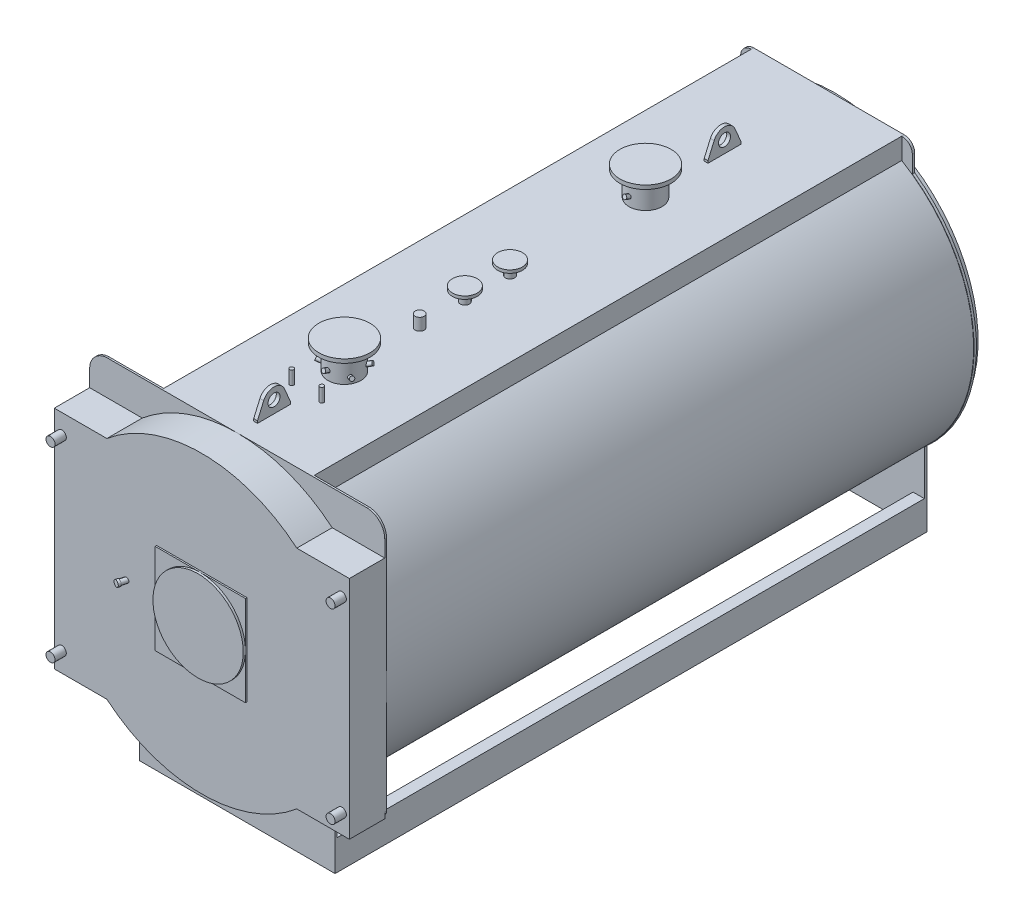
from build123d import *

# Parameters (mm, degrees)
PIASTRA_ANTERIORE_DEPTH       = 12
CORPO_DEPTH                   = 3902
PIASTRA_POSTERIORE_DEPTH      = 16
BASAMENTO_DEPTH               = 3902
ESTRUSIONE_ESTRUSIONE3_DEPTH  = 235
SCHIZZO8_W                    = 600
SCHIZZO8_H                    = 600
ESTRUSIONE_ESTRUSIONE4_DEPTH  = 10
SCHIZZO9_R                    = 300
ESTRUSIONE_ESTRUSIONE5_DEPTH  = 15
SCHIZZO12_R                   = 30
ESTRUSIONE_ESTRUSIONE6_DEPTH  = 75
SCHIZZO13_R                   = 109.55
ESTRUSIONE_ESTRUSIONE7_DEPTH  = 1170
SCHIZZO14_R                   = 170
ESTRUSIONE_ESTRUSIONE8_DEPTH  = 26
SCHIZZO13_3_R                 = 30.15
ESTRUSIONE_ESTRUSIONE9_DEPTH  = 1070
SCHIZZO15_R                   = 82.5
ESTRUSIONE_ESTRUSIONE10_DEPTH = 20
SCHIZZO13_4_R                 = 30.15
ESTRUSIONE_ESTRUSIONE11_DEPTH = 1060
SCHIZZO13_5_R                 = 13.35
ESTRUSIONE_ESTRUSIONE12_DEPTH = 1070
RIPETIZIONECIRCOLARE1_COUNT   = 3
SCHIZZO21_R                   = 24.15
ESTRUSIONE_ESTRUSIONE13_DEPTH = 149
SCHIZZO21_3_R                 = 24.15
ESTRUSIONE_ESTRUSIONE14_DEPTH = 50
SCHIZZO22_R                   = 75
ESTRUSIONE_ESTRUSIONE15_DEPTH = 16
SCHIZZO23_R                   = 40
GOLFARE_DEPTH                 = 12.5


with BuildPart() as part:
    # Schizzo1 → piastra anteriore (new body)
    with BuildSketch(Plane.XY):
        with BuildLine():
            Line((-860, 2210), (860, 2210))
            ThreePointArc((860, 2210), (944.852813742, 2174.852813742), (980, 2090))
            Line((980, 2090), (980, 520))
            ThreePointArc((980, 520), (968.284271247, 491.715728753), (940, 480))
            Line((940, 480), (650, 480))
            Line((650, 480), (650, 0))
            Line((650, 0), (-650, 0))
            Line((-650, 0), (-650, 480))
            Line((-650, 480), (-940, 480))
            ThreePointArc((-940, 480), (-968.284271247, 491.715728753), (-980, 520))
            Line((-980, 520), (-980, 2090))
            ThreePointArc((-980, 2090), (-944.852813742, 2174.852813742), (-860, 2210))
        make_face()
    extrude(amount=-PIASTRA_ANTERIORE_DEPTH)

    # Schizzo2 → corpo (add)
    with BuildSketch(Plane(origin=(0, 0, -12), x_dir=(-1, 0, 0), z_dir=(0, 0, -1))):
        with BuildLine():
            Line((500, 2069.944194575), (500, 2210))
            Line((500, 2210), (-500, 2210))
            Line((-500, 2210), (-500, 2069.944194575))
            ThreePointArc((-500, 2069.944194575), (0, 252.5), (500, 2069.944194575))
        make_face()
        with BuildLine():
            Line((490, 2064.239923523), (490, 2200))
            Line((490, 2200), (-490, 2200))
            Line((-490, 2200), (-490, 2064.239923523))
            ThreePointArc((-490, 2064.239923523), (0, 262.5), (490, 2064.239923523))
        make_face(mode=Mode.SUBTRACT)
    extrude(amount=CORPO_DEPTH)

    # Schizzo3 → piastra posteriore (add)
    with BuildSketch(Plane(origin=(0, 0, -3914), x_dir=(-1, 0, 0), z_dir=(0, 0, -1))):
        with BuildLine():
            Line((-570, 2027.182538695), (-570, 2140))
            ThreePointArc((-570, 2140), (-549.497474683, 2189.497474683), (-500, 2210))
            Line((-500, 2210), (500, 2210))
            ThreePointArc((500, 2210), (549.497474683, 2189.497474683), (570, 2140))
            Line((570, 2140), (570, 2027.182538695))
            ThreePointArc((570, 2027.182538695), (978.664129434, 1281.151947762), (650, 496.583338068))
            Line((650, 496.583338068), (650, 0))
            Line((650, 0), (-650, 0))
            Line((-650, 0), (-650, 496.583338068))
            ThreePointArc((-650, 496.583338068), (-978.664129434, 1281.151947762), (-570, 2027.182538695))
        make_face()
    extrude(amount=PIASTRA_POSTERIORE_DEPTH)

    # Schizzo5 → camera fumo (revolve)
    with BuildSketch(Plane(origin=(0, 0, 0), x_dir=(0, 0, -1), z_dir=(1, 0, 0)), mode=Mode.PRIVATE) as camera_fumo_sk:
        Polygon((3971, 1504), (4074, 1504), (4074, 1545), (4079, 1545), (4079, 1499), (3971, 1499), (3971, 1230), (3930, 1230), (3930, 2180), (3971, 2180), align=None)
    revolve(camera_fumo_sk.sketch.rotate(Axis((0, 1230, -3914), (0, 0, -1)), 90), axis=Axis((0, 1230, -3914), (0, 0, -1)))  # turned: the seam where the file's is

    # Schizzo6 → basamento (add)
    with BuildSketch(Plane(origin=(0, 0, -12), x_dir=(-1, 0, 0), z_dir=(0, 0, -1))):
        Polygon((-575, 0), (-650, 0), (-650, 200), (-575, 200), (-575, 190), (-640, 190), (-640, 10), (-575, 10), align=None)
    basamento = extrude(amount=BASAMENTO_DEPTH)

    # Specchia2: basamento across plane
    add(basamento.mirror(Plane(origin=(0, 0, 0), x_dir=(0, 0, 1), z_dir=(1, 0, 0))))

    # Schizzo7 → Estrusione-Estrusione3 (add)
    with BuildSketch(Plane.XY):
        with BuildLine():
            Line((630.793151516, 1980), (980, 1980))
            Line((980, 1980), (980, 480))
            Line((980, 480), (630.793151516, 480))
            ThreePointArc((630.793151516, 480), (0, 250), (-630.793151516, 480))
            Line((-630.793151516, 480), (-980, 480))
            Line((-980, 480), (-980, 1980))
            Line((-980, 1980), (-630.793151516, 1980))
            ThreePointArc((-630.793151516, 1980), (0, 2210), (630.793151516, 1980))
        make_face()
    extrude(amount=ESTRUSIONE_ESTRUSIONE3_DEPTH)

    # Schizzo8 → Estrusione-Estrusione4 (add)
    with BuildSketch(Plane.XY.offset(235)):
        with Locations((0, 1230)):
            Rectangle(SCHIZZO8_W, SCHIZZO8_H)
    extrude(amount=ESTRUSIONE_ESTRUSIONE4_DEPTH)

    # Schizzo9 → Estrusione-Estrusione5 (add)
    with BuildSketch(Plane.XY.offset(245)):
        with Locations((0, 1230)):
            Circle(SCHIZZO9_R)
    extrude(amount=ESTRUSIONE_ESTRUSIONE5_DEPTH)

    # Schizzo11 → Rivoluzione2 (revolve)
    with BuildSketch(Plane(origin=(0, 1230, 0), x_dir=(1, 0, 0), z_dir=(0, 1, 0)), mode=Mode.PRIVATE) as rivoluzione2_sk:
        Polygon((-515.868693957, -288.251490803), (-497.762357162, -220.677721947), (-481.631395863, -225), (-495.596627936, -277.118955636), (-492.409072709, -277.973058485), (-496.550177431, -293.427871705), align=None)
    revolve(rivoluzione2_sk.sketch.rotate(Axis((-501.6, 1230, 235), (-0.258819045, 0, 0.965925826)), 180), axis=Axis((-501.6, 1230, 235), (-0.258819045, 0, 0.965925826)))  # turned: the seam where the file's is

    # Schizzo12 → Estrusione-Estrusione6 (add)
    with BuildSketch(Plane.XY.offset(235)):
        with Locations((-930, 1850)):
            Circle(SCHIZZO12_R)
        with Locations(Location((930, 1850, 0), (0, 0, 180))):  # turned: the seam where the file's is
            Circle(SCHIZZO12_R)
        with Locations((930, 610)):
            Circle(SCHIZZO12_R)
        with Locations(Location((-930, 610, 0), (0, 0, 180))):  # turned: the seam where the file's is
            Circle(SCHIZZO12_R)
    extrude(amount=ESTRUSIONE_ESTRUSIONE6_DEPTH)

    # Schizzo13 → Estrusione-Estrusione7 (add)
    with BuildSketch(Plane(origin=(0, 1230, 0), x_dir=(1, 0, 0), z_dir=(0, 1, 0))):
        with Locations(Location((0, 712, 0), (0, 0, 270))):  # turned: the seam where the file's is
            Circle(SCHIZZO13_R)
        with Locations(Location((0, 2712, 0), (0, 0, 270))):  # turned: the seam where the file's is
            Circle(SCHIZZO13_R)
    extrude(amount=ESTRUSIONE_ESTRUSIONE7_DEPTH)

    # Schizzo14 → Estrusione-Estrusione8 (add)
    with BuildSketch(Plane(origin=(0, 2400, 0), x_dir=(1, 0, 0), z_dir=(0, 1, 0))):
        with Locations(Location((0, 712, 0), (0, 0, 270))):  # turned: the seam where the file's is
            Circle(SCHIZZO14_R)
        with Locations(Location((0, 2712, 0), (0, 0, 270))):  # turned: the seam where the file's is
            Circle(SCHIZZO14_R)
    extrude(amount=-ESTRUSIONE_ESTRUSIONE8_DEPTH)

    # Schizzo13_3 → Estrusione-Estrusione9 (add)
    with BuildSketch(Plane(origin=(0, 1230, 0), x_dir=(1, 0, 0), z_dir=(0, 1, 0))):
        with Locations(Location((0, 1812, 0), (0, 0, 270))):  # turned: the seam where the file's is
            Circle(SCHIZZO13_3_R)
        with Locations(Location((0, 1512, 0), (0, 0, 270))):  # turned: the seam where the file's is
            Circle(SCHIZZO13_3_R)
    extrude(amount=ESTRUSIONE_ESTRUSIONE9_DEPTH)

    # Schizzo15 → Estrusione-Estrusione10 (add)
    with BuildSketch(Plane(origin=(0, 2300, 0), x_dir=(1, 0, 0), z_dir=(0, 1, 0))):
        with Locations(Location((0, 1812, 0), (0, 0, 270))):  # turned: the seam where the file's is
            Circle(SCHIZZO15_R)
        with Locations(Location((0, 1512, 0), (0, 0, 270))):  # turned: the seam where the file's is
            Circle(SCHIZZO15_R)
    extrude(amount=-ESTRUSIONE_ESTRUSIONE10_DEPTH)

    # Schizzo13_4 → Estrusione-Estrusione11 (add)
    with BuildSketch(Plane(origin=(0, 1230, 0), x_dir=(1, 0, 0), z_dir=(0, 1, 0))):
        with Locations(Location((0, 1212, 0), (0, 0, 270))):  # turned: the seam where the file's is
            Circle(SCHIZZO13_4_R)
    extrude(amount=ESTRUSIONE_ESTRUSIONE11_DEPTH)

    # Schizzo13_5 → Estrusione-Estrusione12 (add)
    with BuildSketch(Plane(origin=(0, 1230, 0), x_dir=(1, 0, 0), z_dir=(0, 1, 0))):
        with Locations(Location((-100, 462, 0), (0, 0, 270))):  # turned: the seam where the file's is
            Circle(SCHIZZO13_5_R)
        with Locations(Location((100, 462, 0), (0, 0, 270))):  # turned: the seam where the file's is
            Circle(SCHIZZO13_5_R)
    extrude(amount=ESTRUSIONE_ESTRUSIONE12_DEPTH)

    # Schizzo16 → Rivoluzione3 (revolve)
    with BuildSketch(Plane(origin=(0, 0, 0), x_dir=(0, 0, -1), z_dir=(1, 0, 0))):
        Polygon((2573.149829072, 2280.664390077), (2577.75, 2293.303255826), (2624.734631039, 2276.20224866), (2620.134460112, 2263.56338291), align=None)
    revolve(axis=Axis((0, 2270, -2602.45), (0, 0.342020143, 0.939692621)))

    # Schizzo17 → Rivoluzione4 (revolve)
    with BuildSketch(Plane(origin=(0, 0, 0), x_dir=(0, 0, -1), z_dir=(1, 0, 0))):
        Polygon((573.149829072, 2280.664390077), (577.75, 2293.303255826), (624.734631039, 2276.20224866), (620.134460112, 2263.56338291), align=None)
    rivoluzione4 = revolve(axis=Axis((0, 2270, -602.45), (0, 0.342020143, 0.939692621)))

    # Schizzo18 → Rivoluzione5 (revolve)
    with BuildSketch(Plane(origin=(0, 0, 0), x_dir=(0, 0, -1), z_dir=(1, 0, 0)), mode=Mode.PRIVATE) as rivoluzione5_sk:
        Polygon((850.850170928, 2260.664390077), (846.25, 2273.303255826), (799.265368961, 2256.20224866), (803.865539888, 2243.56338291), align=None)
    rivoluzione5 = revolve(rivoluzione5_sk.sketch.rotate(Axis((0, 2250, -821.55), (0, 0.342020143, -0.939692621)), 180), axis=Axis((0, 2250, -821.55), (0, 0.342020143, -0.939692621)))  # turned: the seam where the file's is

    # RipetizioneCircolare1: Rivoluzione4, Rivoluzione5 ×3 about axis
    ripetizionecircolare1_axis = Axis((0, 0, -712), (0, 1, 0))
    add([rivoluzione4.rotate(ripetizionecircolare1_axis, i * 360 / RIPETIZIONECIRCOLARE1_COUNT) for i in range(1, RIPETIZIONECIRCOLARE1_COUNT)])
    add([rivoluzione5.rotate(ripetizionecircolare1_axis, i * 360 / RIPETIZIONECIRCOLARE1_COUNT) for i in range(1, RIPETIZIONECIRCOLARE1_COUNT)])

    # Schizzo21 → Estrusione-Estrusione13 (add)
    with BuildSketch(Plane(origin=(0, 0, -3930), x_dir=(-1, 0, 0), z_dir=(0, 0, -1))):
        with Locations((0, 125)):
            Circle(SCHIZZO21_R)
    extrude(amount=ESTRUSIONE_ESTRUSIONE13_DEPTH)

    # Schizzo21_3 → Estrusione-Estrusione14 (add)
    with BuildSketch(Plane(origin=(0, 0, -3930), x_dir=(-1, 0, 0), z_dir=(0, 0, -1))):
        with Locations(Location((0, 260, 0), (0, 0, 123.688228426))):  # turned: the seam where the file's is
            Circle(SCHIZZO21_3_R)
    extrude(amount=ESTRUSIONE_ESTRUSIONE14_DEPTH)

    # Schizzo22 → Estrusione-Estrusione15 (add)
    with BuildSketch(Plane(origin=(0, 0, -4079), x_dir=(-1, 0, 0), z_dir=(0, 0, -1))):
        with Locations((0, 125)):
            Circle(SCHIZZO22_R)
    extrude(amount=-ESTRUSIONE_ESTRUSIONE15_DEPTH)

    # Schizzo23 → golfare (add, symmetric)
    with BuildSketch(Plane(origin=(0, 0, 0), x_dir=(0, 0, -1), z_dir=(1, 0, 0))):
        with BuildLine():
            Line((122, 2145), (122, 2225))
            Line((122, 2225), (163.208335614, 2319.878201268))
            ThreePointArc((163.208335614, 2319.878201268), (232, 2365), (300.791664386, 2319.878201268))
            Line((300.791664386, 2319.878201268), (342, 2225))
            Line((342, 2225), (342, 2145))
            Line((342, 2145), (122, 2145))
        make_face()
        with Locations((232, 2290)):
            Circle(SCHIZZO23_R, mode=Mode.SUBTRACT)
        with BuildLine():
            Line((3114, 2145), (3114, 2225))
            Line((3114, 2225), (3155.208335614, 2319.878201268))
            ThreePointArc((3155.208335614, 2319.878201268), (3224, 2365), (3292.791664386, 2319.878201268))
            Line((3292.791664386, 2319.878201268), (3334, 2225))
            Line((3334, 2225), (3334, 2145))
            Line((3334, 2145), (3114, 2145))
        make_face()
        with Locations((3224, 2290)):
            Circle(SCHIZZO23_R, mode=Mode.SUBTRACT)
    extrude(amount=GOLFARE_DEPTH, both=True)


solid = part.part
